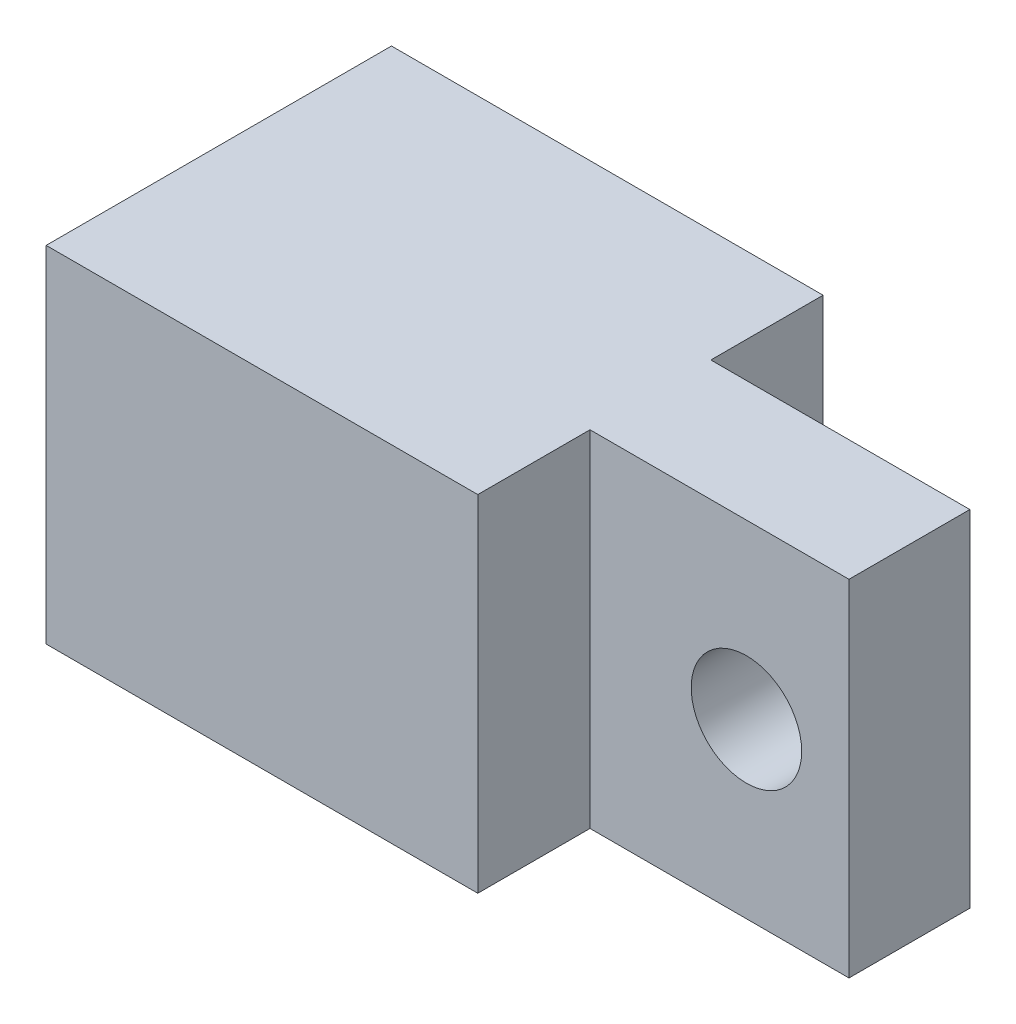
from build123d import *

# Parameters (mm, degrees)
BOSS_EXTRUDE1_DEPTH = 10
SKETCH4_R           = 1.6
CUT_EXTRUDE2_DEPTH  = 7.75


with BuildPart() as part:
    # Sketch1 → Boss-Extrude1 (new body)
    with BuildSketch(Plane(origin=(0, 0, 0), x_dir=(1, 0, 0), z_dir=(0, 1, 0))):
        Polygon((6.25, 5), (6.25, 1.75), (13.75, 1.75), (13.75, -1.75), (6.25, -1.75), (6.25, -5), (-6.25, -5), (-6.25, 5), align=None)
    extrude(amount=BOSS_EXTRUDE1_DEPTH)

    # Sketch4 → Cut-Extrude2 (cut, through all)
    with BuildSketch(Plane.XY.offset(1.75)):
        with Locations((10.780263086, 5)):
            Circle(SKETCH4_R)
    extrude(amount=-CUT_EXTRUDE2_DEPTH, mode=Mode.SUBTRACT)


solid = part.part
